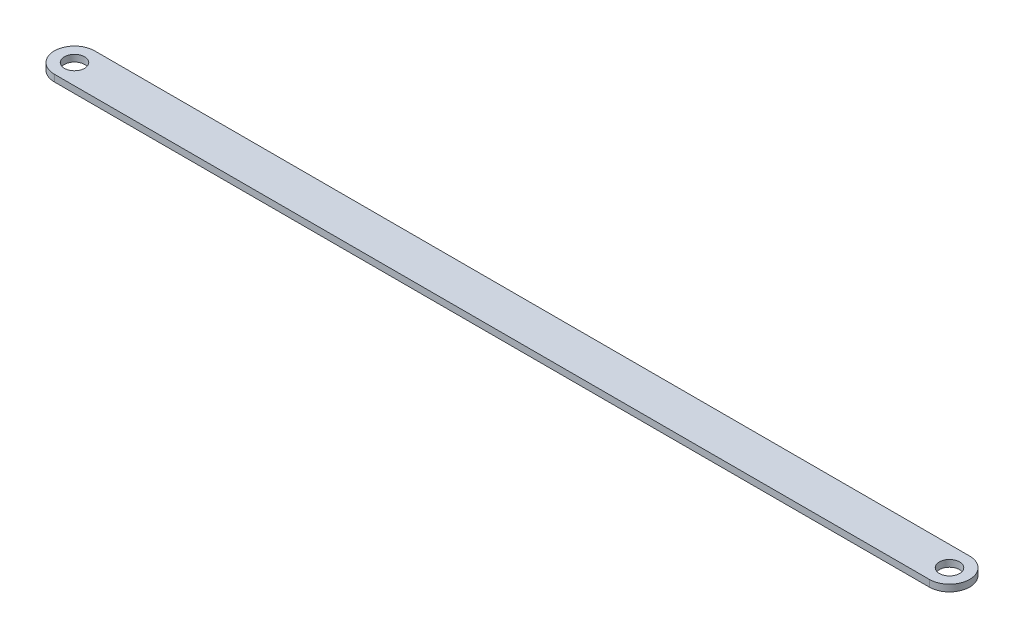
from build123d import *

# Parameters (mm, degrees)
SKETCH1_R           = 1.5
BOSS_EXTRUDE1_DEPTH = 1


with BuildPart() as part:
    # Sketch1 → Boss-Extrude1 (new body)
    with BuildSketch(Plane(origin=(0, 0, 0), x_dir=(1, 0, 0), z_dir=(0, 1, 0))):
        with BuildLine():
            Line((65, -3), (-65, -3))
            ThreePointArc((-65, -3), (-68, 0), (-65, 3))
            Line((-65, 3), (65, 3))
            ThreePointArc((65, 3), (68, 0), (65, -3))
        make_face()
        with Locations((-65, 0)):
            Circle(SKETCH1_R, mode=Mode.SUBTRACT)
        with Locations((65, 0)):
            Circle(SKETCH1_R, mode=Mode.SUBTRACT)
    extrude(amount=BOSS_EXTRUDE1_DEPTH)


solid = part.part
